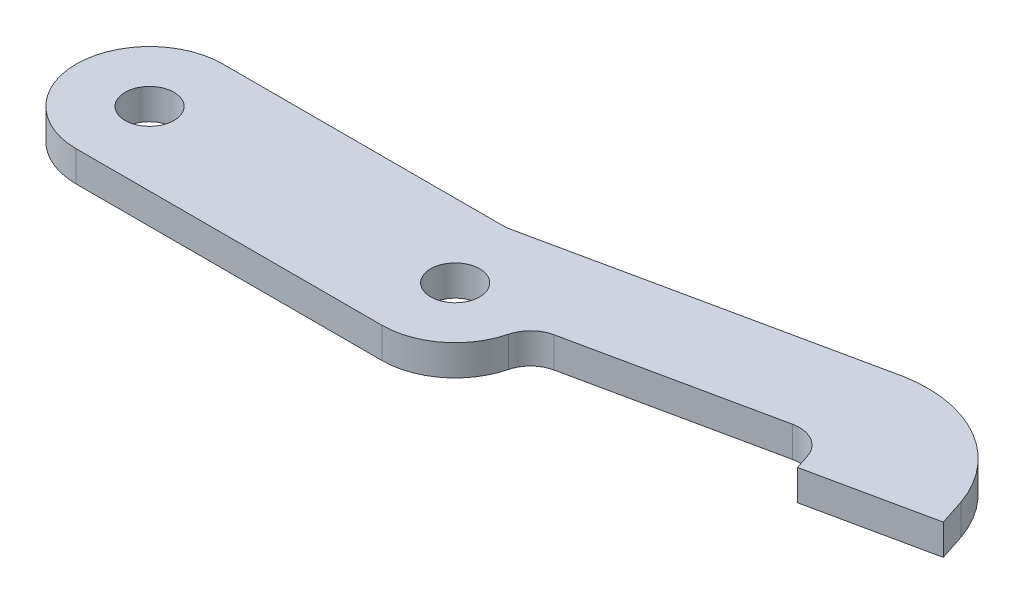
from build123d import *

# Parameters (mm, degrees)
SKETCH1_R           = 4
BOSS_EXTRUDE1_DEPTH = 5
FILLET1_R           = 5
SCALE1_SCALE        = 0.5


with BuildPart() as part:
    # Sketch1 → Boss-Extrude1 (new body)
    with BuildSketch(Plane(origin=(0, 0, 0), x_dir=(1, 0, 0), z_dir=(0, 1, 0))):
        with BuildLine():
            Line((0, 12), (46.309546143, 12))
            Line((46.309546143, 12), (100.107664183, 23.435142995))
            ThreePointArc((100.107664183, 23.435142995), (113.686830565, 20.974303457), (122.439553034, 10.304751439))
            Line((122.439553034, 10.304751439), (123.826560512, 6.023839123))
            Line((123.826560512, 6.023839123), (104.157567187, 1.843065531))
            Line((104.157567187, 1.843065531), (102, 8.502262467))
            Line((102, 8.502262467), (62, 0))
            ThreePointArc((62, 0), (58.485281374, -8.485281374), (50, -12))
            Line((50, -12), (0, -12))
            ThreePointArc((0, -12), (-12, 0), (0, 12))
        make_face()
        Circle(SKETCH1_R, mode=Mode.SUBTRACT)
        with Locations((50, 0)):
            Circle(SKETCH1_R, mode=Mode.SUBTRACT)
    extrude(amount=BOSS_EXTRUDE1_DEPTH)

    # Fillet1
    fillet1_edges = [part.edges().sort_by_distance(p)[0] for p in [
        (102, 2.5, -8.502262467),
        (62, 2.5, 0),
        (46.309546143, 2.5, -12),
    ]]
    fillet(fillet1_edges, radius=FILLET1_R)


with BuildPart() as part_1:
    # Scale1: scaled about (50.856755606, 2.5, -4.748712571)
    add(part.part.scale(SCALE1_SCALE).moved(Location((25.428377803, 1.25, -2.374356286))))


solid = part_1.part
